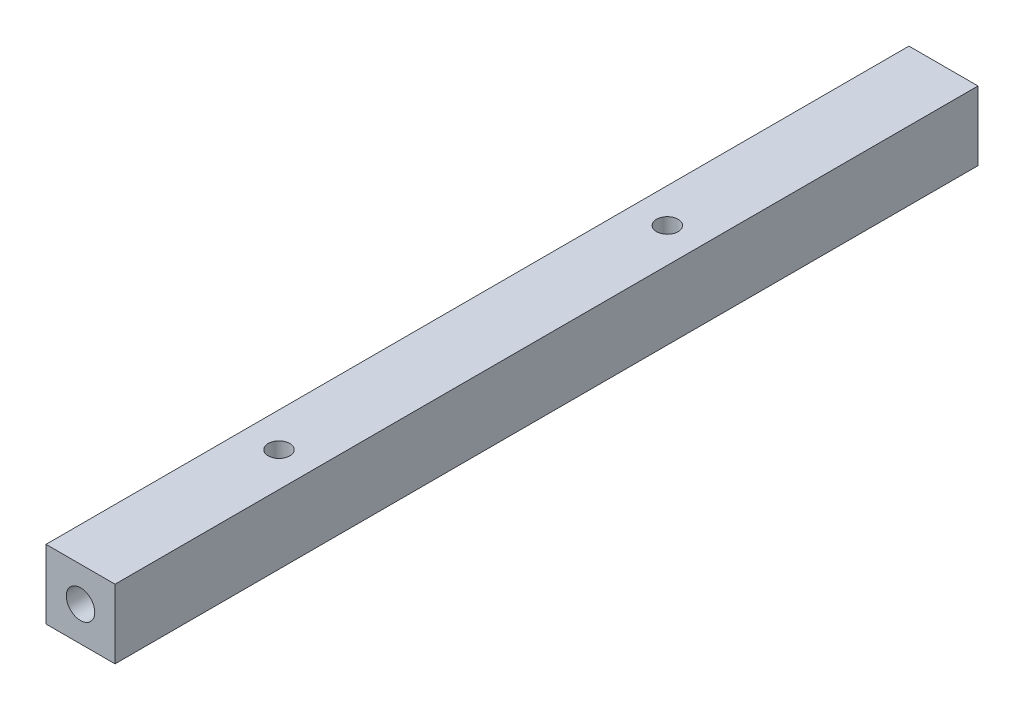
from build123d import *

# Parameters (mm, degrees)
SKETCH1_W                       = 8
SKETCH1_H                       = 8
EXTRUDE1_DEPTH                  = 100
M3_TAPPED_HOLE1_D               = 2.5
M4_TAPPED_HOLE1_D               = 3.3
M4_TAPPED_HOLE1_DEPTH           = 10
M4_TAPPED_HOLE1_TIP             = 0.991420021
M4_TAPPED_HOLE1_ON_FACE_2_D     = 3.3
M4_TAPPED_HOLE1_ON_FACE_2_DEPTH = 10
M4_TAPPED_HOLE1_ON_FACE_2_TIP   = 0.991420021


with BuildPart() as part:
    # Sketch1 → Extrude1 (new body)
    with BuildSketch(Plane.XY):
        with Locations((4, 4)):
            Rectangle(SKETCH1_W, SKETCH1_H)
    extrude(amount=EXTRUDE1_DEPTH)

    # M3 Tapped Hole1 (through all)
    with Locations(Plane(origin=(4, 8, 77), x_dir=(0, 0, 1), z_dir=(0, 1, 0))):
        with Locations((0, 0), (-45, 0)):
            Hole(M3_TAPPED_HOLE1_D / 2)

    # M4 Tapped Hole1
    with Locations(Plane(origin=(4, 4, 0), x_dir=(-1, 0, 0), z_dir=(0, 0, -1))):
        with Locations((0, 0)):
            Hole(M4_TAPPED_HOLE1_D / 2, depth=M4_TAPPED_HOLE1_DEPTH)
            with Locations((0, 0, -(M4_TAPPED_HOLE1_DEPTH + M4_TAPPED_HOLE1_TIP / 2))):  # 118° drill point
                Cone(0, M4_TAPPED_HOLE1_D / 2, M4_TAPPED_HOLE1_TIP, mode=Mode.SUBTRACT)

    # M4 Tapped Hole1 on face 2
    with Locations(Plane(origin=(4, 4, 100), x_dir=(1, 0, 0), z_dir=(0, 0, 1))):
        with Locations((0, 0)):
            Hole(M4_TAPPED_HOLE1_ON_FACE_2_D / 2, depth=M4_TAPPED_HOLE1_ON_FACE_2_DEPTH)
            with Locations((0, 0, -(M4_TAPPED_HOLE1_ON_FACE_2_DEPTH + M4_TAPPED_HOLE1_ON_FACE_2_TIP / 2))):  # 118° drill point
                Cone(0, M4_TAPPED_HOLE1_ON_FACE_2_D / 2, M4_TAPPED_HOLE1_ON_FACE_2_TIP, mode=Mode.SUBTRACT)


solid = part.part
